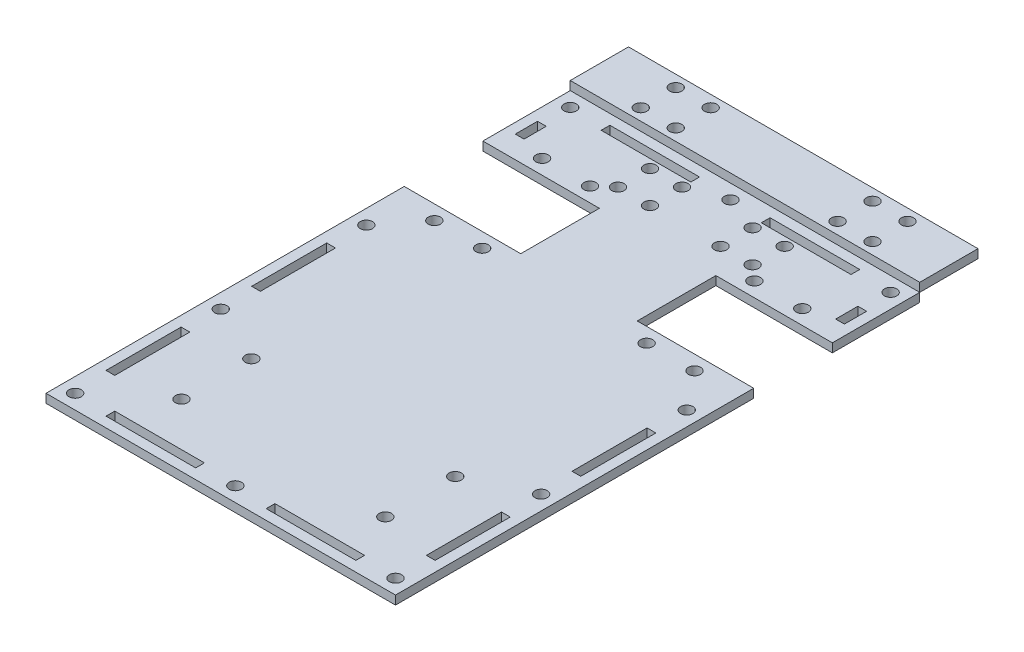
from build123d import *

# Parameters (mm, degrees)
BOSS_EXTRUDE1_DEPTH                     = 3
HOLE_FOR_M3_300_SC_NUTS_SP_1_D          = 4.22
HOLE_FOR_M3_300_SC_NUTS_SP_2_D          = 4.22
HOLE_FOR_M3_300_SC_NUTS_SP_3_D          = 4.22
HOLE_FOR_M3_300_SC_NUTS_SP_4_D          = 4.22
HOLE_FOR_M3_300_SC_NUTS_SP_5_D          = 4.22
SKETCH15_W                              = 30.78
SKETCH15_H                              = 3
SKETCH15_W_2                            = 3
SKETCH15_H_2                            = 7.63
SKETCH15_H_3                            = 25.78
CUT_EXTRUDE1_DEPTH                      = 4
SKETCH16_W                              = 120
SKETCH16_H                              = 20
BOSS_EXTRUDE3_DEPTH                     = 3
SKETCH19_W                              = 2.11
SKETCH19_H                              = 6
HOLE_FOR_M3_300_SC_NUTS_SP_6_AT_2_COUNT = 2
HOLE_FOR_M3_300_SC_NUTS_SP_6_AT_2_PITCH = 12
HOLE_FOR_M3_300_SC_NUTS_SP_6_AT_3_COUNT = 2
HOLE_FOR_M3_300_SC_NUTS_SP_6_AT_3_PITCH = 12
HOLE_FOR_M3_300_SC_NUTS_SP_6_AT_4_COUNT = 2
HOLE_FOR_M3_300_SC_NUTS_SP_6_AT_4_PITCH = 16.970562748
HOLE_FOR_M3_300_SC_NUTS_SP_6_AT_5_COUNT = 2
HOLE_FOR_M3_300_SC_NUTS_SP_6_AT_5_PITCH = 79.58
HOLE_FOR_M3_300_SC_NUTS_SP_6_AT_6_COUNT = 2
HOLE_FOR_M3_300_SC_NUTS_SP_6_AT_6_PITCH = 67.58
HOLE_FOR_M3_300_SC_NUTS_SP_6_AT_7_COUNT = 2
HOLE_FOR_M3_300_SC_NUTS_SP_6_AT_7_PITCH = 68.637135721
HOLE_FOR_M3_300_SC_NUTS_SP_6_AT_8_COUNT = 2
HOLE_FOR_M3_300_SC_NUTS_SP_6_AT_8_PITCH = 80.479664512
SKETCH30_W                              = 2.11
SKETCH30_H                              = 3
HOLE_FOR_M3_300_SC_NUTS_SP_8_AT_2_COUNT = 2
HOLE_FOR_M3_300_SC_NUTS_SP_8_AT_2_PITCH = 11
HOLE_FOR_M3_300_SC_NUTS_SP_8_AT_3_COUNT = 2
HOLE_FOR_M3_300_SC_NUTS_SP_8_AT_3_PITCH = 15.556349186
HOLE_FOR_M3_300_SC_NUTS_SP_8_AT_4_COUNT = 2
HOLE_FOR_M3_300_SC_NUTS_SP_8_AT_4_PITCH = 11
HOLE_FOR_M3_300_SC_NUTS_SP_8_AT_5_COUNT = 2
HOLE_FOR_M3_300_SC_NUTS_SP_8_AT_5_PITCH = 35.22
HOLE_FOR_M3_300_SC_NUTS_SP_8_AT_6_COUNT = 2
HOLE_FOR_M3_300_SC_NUTS_SP_8_AT_6_PITCH = 46.22
HOLE_FOR_M3_300_SC_NUTS_SP_8_AT_7_COUNT = 2
HOLE_FOR_M3_300_SC_NUTS_SP_8_AT_7_PITCH = 47.510929269
HOLE_FOR_M3_300_SC_NUTS_SP_8_AT_8_COUNT = 2
HOLE_FOR_M3_300_SC_NUTS_SP_8_AT_8_PITCH = 36.897810233
SKETCH31_W                              = 40
SKETCH31_H                              = 13
BOSS_EXTRUDE4_DEPTH                     = 3
BOSS_EXTRUDE4_2_DEPTH                   = 3
SKETCH34_W                              = 2.11
SKETCH34_H                              = 3
HOLE_FOR_M3_300_SC_NUTS_SP_9_AT_2_COUNT = 2
HOLE_FOR_M3_300_SC_NUTS_SP_9_AT_2_PITCH = 16.445
HOLE_FOR_M3_300_SC_NUTS_SP_9_AT_3_COUNT = 2
HOLE_FOR_M3_300_SC_NUTS_SP_9_AT_3_PITCH = 72.89
HOLE_FOR_M3_300_SC_NUTS_SP_9_AT_4_COUNT = 2
HOLE_FOR_M3_300_SC_NUTS_SP_9_AT_4_PITCH = 89.335
SKETCH35_W                              = 4.082372286
SKETCH35_H                              = 14.550345667
SKETCH35_W_2                            = 4.333493725
BOSS_EXTRUDE5_DEPTH                     = 3


with BuildPart() as part:
    # Sketch1 → Boss-Extrude1 (new body)
    with BuildSketch(Plane(origin=(0, 0, 0), x_dir=(1, 0, 0), z_dir=(0, 1, 0))):
        Polygon((0, 0), (120, 0), (120, 110), (80, 110), (80, 150), (120, 150), (120, 180), (0, 180), (0, 150), (40, 150), (40, 110), (0, 110), align=None)
    extrude(amount=BOSS_EXTRUDE1_DEPTH)

    # Hole for M3 300® SC Nuts (SP)1 (through all)
    with Locations(Plane(origin=(0, 3, 0), x_dir=(1, 0, 0), z_dir=(0, 1, 0))):
        with Locations((5, 175), (60, 175), (115, 175), (115, 5), (60, 5), (5, 5)):
            Hole(HOLE_FOR_M3_300_SC_NUTS_SP_1_D / 2)

    # Hole for M3 300® SC Nuts (SP)2 (through all)
    with Locations(Plane(origin=(0, 3, 0), x_dir=(1, 0, 0), z_dir=(0, 1, 0))):
        with Locations((5, 105), (115, 105)):
            Hole(HOLE_FOR_M3_300_SC_NUTS_SP_2_D / 2)

    # Hole for M3 300® SC Nuts (SP)3 (through all)
    with Locations(Plane(origin=(0, 3, 0), x_dir=(1, 0, 0), z_dir=(0, 1, 0))):
        with Locations((115, 55), (5, 55)):
            Hole(HOLE_FOR_M3_300_SC_NUTS_SP_3_D / 2)

    # Hole for M3 300® SC Nuts (SP)4 (through all)
    with Locations(Plane(origin=(0, 3, 0), x_dir=(1, 0, 0), z_dir=(0, 1, 0))):
        with Locations((88.2225, 155), (104.6675, 155), (15.3325, 155), (31.7775, 155)):
            Hole(HOLE_FOR_M3_300_SC_NUTS_SP_4_D / 2)

    # Hole for M3 300® SC Nuts (SP)5 (through all)
    with Locations(Plane(origin=(0, 3, 0), x_dir=(1, 0, 0), z_dir=(0, 1, 0))):
        with Locations((25, 45.5), (95, 45.5), (95, 21.5), (25, 21.5)):
            Hole(HOLE_FOR_M3_300_SC_NUTS_SP_5_D / 2)

    # Sketch15 → Cut-Extrude1 (cut, through all)
    with BuildSketch(Plane(origin=(0, 3, 0), x_dir=(1, 0, 0), z_dir=(0, 1, 0))):
        with Locations((87.5, 175)):
            Rectangle(SKETCH15_W, SKETCH15_H)
        with Locations((32.5, 175)):
            Rectangle(SKETCH15_W, SKETCH15_H)
        with Locations((5, 161.445)):
            Rectangle(SKETCH15_W_2, SKETCH15_H_2)
        with Locations((115, 161.445)):
            Rectangle(SKETCH15_W_2, SKETCH15_H_2)
        with Locations((5, 80)):
            Rectangle(SKETCH15_W_2, SKETCH15_H_3)
        with Locations((115, 80)):
            Rectangle(SKETCH15_W_2, SKETCH15_H_3)
        with Locations((115, 30)):
            Rectangle(SKETCH15_W_2, SKETCH15_H_3)
        with Locations((5, 30)):
            Rectangle(SKETCH15_W_2, SKETCH15_H_3)
        with Locations((32.5, 5)):
            Rectangle(SKETCH15_W, SKETCH15_H)
        with Locations((87.5, 5)):
            Rectangle(SKETCH15_W, SKETCH15_H)
    extrude(amount=-CUT_EXTRUDE1_DEPTH, mode=Mode.SUBTRACT)

    # Sketch30 → Hole for M3 300® SC Nuts (SP)8 (revolve, cut)
    with BuildSketch(Plane(origin=(36.89, 3, -159.5), x_dir=(0, 0, 1), z_dir=(1, 0, 0))):
        with Locations((1.055, 1.5)):
            Rectangle(SKETCH30_W, SKETCH30_H)
    hole_for_m3_300_sc_nuts_sp_8 = revolve(axis=Axis((36.89, 9.35, -159.5), (0, -1, 0)), mode=Mode.SUBTRACT)

    # Hole for M3 300® SC Nuts (SP)8 at 2: Hole for M3 300® SC Nuts (SP)8 ×2
    with Locations(*[(0, 0, -i * HOLE_FOR_M3_300_SC_NUTS_SP_8_AT_2_PITCH) for i in range(1, HOLE_FOR_M3_300_SC_NUTS_SP_8_AT_2_COUNT)]):
        add(hole_for_m3_300_sc_nuts_sp_8, mode=Mode.SUBTRACT)

    # Hole for M3 300® SC Nuts (SP)8 at 3: Hole for M3 300® SC Nuts (SP)8 ×2
    with Locations(*[Vector(0.707106781, 0, -0.707106781) * (i * HOLE_FOR_M3_300_SC_NUTS_SP_8_AT_3_PITCH) for i in range(1, HOLE_FOR_M3_300_SC_NUTS_SP_8_AT_3_COUNT)]):
        add(hole_for_m3_300_sc_nuts_sp_8, mode=Mode.SUBTRACT)

    # Hole for M3 300® SC Nuts (SP)8 at 4: Hole for M3 300® SC Nuts (SP)8 ×2
    with Locations(*[(i * HOLE_FOR_M3_300_SC_NUTS_SP_8_AT_4_PITCH, 0, 0) for i in range(1, HOLE_FOR_M3_300_SC_NUTS_SP_8_AT_4_COUNT)]):
        add(hole_for_m3_300_sc_nuts_sp_8, mode=Mode.SUBTRACT)

    # Hole for M3 300® SC Nuts (SP)8 at 5: Hole for M3 300® SC Nuts (SP)8 ×2
    with Locations(*[(i * HOLE_FOR_M3_300_SC_NUTS_SP_8_AT_5_PITCH, 0, 0) for i in range(1, HOLE_FOR_M3_300_SC_NUTS_SP_8_AT_5_COUNT)]):
        add(hole_for_m3_300_sc_nuts_sp_8, mode=Mode.SUBTRACT)

    # Hole for M3 300® SC Nuts (SP)8 at 6: Hole for M3 300® SC Nuts (SP)8 ×2
    with Locations(*[(i * HOLE_FOR_M3_300_SC_NUTS_SP_8_AT_6_PITCH, 0, 0) for i in range(1, HOLE_FOR_M3_300_SC_NUTS_SP_8_AT_6_COUNT)]):
        add(hole_for_m3_300_sc_nuts_sp_8, mode=Mode.SUBTRACT)

    # Hole for M3 300® SC Nuts (SP)8 at 7: Hole for M3 300® SC Nuts (SP)8 ×2
    with Locations(*[Vector(0.972828794, 0, -0.231525676) * (i * HOLE_FOR_M3_300_SC_NUTS_SP_8_AT_7_PITCH) for i in range(1, HOLE_FOR_M3_300_SC_NUTS_SP_8_AT_7_COUNT)]):
        add(hole_for_m3_300_sc_nuts_sp_8, mode=Mode.SUBTRACT)

    # Hole for M3 300® SC Nuts (SP)8 at 8: Hole for M3 300® SC Nuts (SP)8 ×2
    with Locations(*[Vector(0.95452819, 0, -0.298120672) * (i * HOLE_FOR_M3_300_SC_NUTS_SP_8_AT_8_PITCH) for i in range(1, HOLE_FOR_M3_300_SC_NUTS_SP_8_AT_8_COUNT)]):
        add(hole_for_m3_300_sc_nuts_sp_8, mode=Mode.SUBTRACT)



with BuildPart() as body_2:
    # Sketch16 → Boss-Extrude3 (new body)
    with BuildSketch(Plane(origin=(0, 3, 0), x_dir=(1, 0, 0), z_dir=(0, 1, 0))):
        with Locations((60, 190)):
            Rectangle(SKETCH16_W, SKETCH16_H)
    extrude(amount=BOSS_EXTRUDE3_DEPTH)

    # Sketch19 → Hole for M3 300® SC Nuts (SP)6 (revolve, cut)
    with BuildSketch(Plane(origin=(20.21, 6, -196), x_dir=(0, 0, 1), z_dir=(1, 0, 0))):
        with Locations((1.055, 3)):
            Rectangle(SKETCH19_W, SKETCH19_H)
    hole_for_m3_300_sc_nuts_sp_6 = revolve(axis=Axis((20.21, 12.35, -196), (0, -1, 0)), mode=Mode.SUBTRACT)

    # Hole for M3 300® SC Nuts (SP)6 at 2: Hole for M3 300® SC Nuts (SP)6 ×2
    with Locations(*[(i * HOLE_FOR_M3_300_SC_NUTS_SP_6_AT_2_PITCH, 0, 0) for i in range(1, HOLE_FOR_M3_300_SC_NUTS_SP_6_AT_2_COUNT)]):
        add(hole_for_m3_300_sc_nuts_sp_6, mode=Mode.SUBTRACT)

    # Hole for M3 300® SC Nuts (SP)6 at 3: Hole for M3 300® SC Nuts (SP)6 ×2
    with Locations(*[(0, 0, i * HOLE_FOR_M3_300_SC_NUTS_SP_6_AT_3_PITCH) for i in range(1, HOLE_FOR_M3_300_SC_NUTS_SP_6_AT_3_COUNT)]):
        add(hole_for_m3_300_sc_nuts_sp_6, mode=Mode.SUBTRACT)

    # Hole for M3 300® SC Nuts (SP)6 at 4: Hole for M3 300® SC Nuts (SP)6 ×2
    with Locations(*[Vector(0.707106781, 0, 0.707106781) * (i * HOLE_FOR_M3_300_SC_NUTS_SP_6_AT_4_PITCH) for i in range(1, HOLE_FOR_M3_300_SC_NUTS_SP_6_AT_4_COUNT)]):
        add(hole_for_m3_300_sc_nuts_sp_6, mode=Mode.SUBTRACT)

    # Hole for M3 300® SC Nuts (SP)6 at 5: Hole for M3 300® SC Nuts (SP)6 ×2
    with Locations(*[(i * HOLE_FOR_M3_300_SC_NUTS_SP_6_AT_5_PITCH, 0, 0) for i in range(1, HOLE_FOR_M3_300_SC_NUTS_SP_6_AT_5_COUNT)]):
        add(hole_for_m3_300_sc_nuts_sp_6, mode=Mode.SUBTRACT)

    # Hole for M3 300® SC Nuts (SP)6 at 6: Hole for M3 300® SC Nuts (SP)6 ×2
    with Locations(*[(i * HOLE_FOR_M3_300_SC_NUTS_SP_6_AT_6_PITCH, 0, 0) for i in range(1, HOLE_FOR_M3_300_SC_NUTS_SP_6_AT_6_COUNT)]):
        add(hole_for_m3_300_sc_nuts_sp_6, mode=Mode.SUBTRACT)

    # Hole for M3 300® SC Nuts (SP)6 at 7: Hole for M3 300® SC Nuts (SP)6 ×2
    with Locations(*[Vector(0.984598196, 0, 0.17483247) * (i * HOLE_FOR_M3_300_SC_NUTS_SP_6_AT_7_PITCH) for i in range(1, HOLE_FOR_M3_300_SC_NUTS_SP_6_AT_7_COUNT)]):
        add(hole_for_m3_300_sc_nuts_sp_6, mode=Mode.SUBTRACT)

    # Hole for M3 300® SC Nuts (SP)6 at 8: Hole for M3 300® SC Nuts (SP)6 ×2
    with Locations(*[Vector(0.988821219, 0, 0.149105989) * (i * HOLE_FOR_M3_300_SC_NUTS_SP_6_AT_8_PITCH) for i in range(1, HOLE_FOR_M3_300_SC_NUTS_SP_6_AT_8_COUNT)]):
        add(hole_for_m3_300_sc_nuts_sp_6, mode=Mode.SUBTRACT)


with BuildPart() as body_3:
    # Sketch31 → Boss-Extrude4 (new body)
    with BuildSketch(Plane(origin=(0, 3, 0), x_dir=(1, 0, 0), z_dir=(0, 1, 0))):
        with Locations((20, 116.5)):
            Rectangle(SKETCH31_W, SKETCH31_H)
    extrude(amount=-BOSS_EXTRUDE4_DEPTH)

    # Sketch34 → Hole for M3 300® SC Nuts (SP)9 (revolve, cut)
    with BuildSketch(Plane(origin=(15.3325, 3, -118), x_dir=(0, 0, 1), z_dir=(1, 0, 0))):
        with Locations((1.055, 1.5)):
            Rectangle(SKETCH34_W, SKETCH34_H)
    hole_for_m3_300_sc_nuts_sp_9 = revolve(axis=Axis((15.3325, 9.35, -118), (0, -1, 0)), mode=Mode.SUBTRACT)

    # Hole for M3 300® SC Nuts (SP)9 at 2: Hole for M3 300® SC Nuts (SP)9 ×2
    with Locations(*[(i * HOLE_FOR_M3_300_SC_NUTS_SP_9_AT_2_PITCH, 0, 0) for i in range(1, HOLE_FOR_M3_300_SC_NUTS_SP_9_AT_2_COUNT)]):
        add(hole_for_m3_300_sc_nuts_sp_9, mode=Mode.SUBTRACT)


with BuildPart() as body_4:
    # Sketch31 → Boss-Extrude4 2 (new body)
    with BuildSketch(Plane(origin=(0, 3, 0), x_dir=(1, 0, 0), z_dir=(0, 1, 0))):
        with Locations((100, 116.5)):
            Rectangle(SKETCH31_W, SKETCH31_H)
    extrude(amount=-BOSS_EXTRUDE4_2_DEPTH)

    # Hole for M3 300® SC Nuts (SP)9 at 3: Hole for M3 300® SC Nuts (SP)9 ×2
    with Locations(*[(i * HOLE_FOR_M3_300_SC_NUTS_SP_9_AT_3_PITCH, 0, 0) for i in range(1, HOLE_FOR_M3_300_SC_NUTS_SP_9_AT_3_COUNT)]):
        add(hole_for_m3_300_sc_nuts_sp_9, mode=Mode.SUBTRACT)

    # Hole for M3 300® SC Nuts (SP)9 at 4: Hole for M3 300® SC Nuts (SP)9 ×2
    with Locations(*[(i * HOLE_FOR_M3_300_SC_NUTS_SP_9_AT_4_PITCH, 0, 0) for i in range(1, HOLE_FOR_M3_300_SC_NUTS_SP_9_AT_4_COUNT)]):
        add(hole_for_m3_300_sc_nuts_sp_9, mode=Mode.SUBTRACT)


with BuildPart() as part_1:
    add(part.part)

    add(body_3.part)  # Boss-Extrude5 merges body 3

    add(body_4.part)  # Boss-Extrude5 merges body 4
    # Sketch35 → Boss-Extrude5 (add)
    with BuildSketch(Plane(origin=(0, 3, 0), x_dir=(1, 0, 0), z_dir=(0, 1, 0))):
        with Locations((39.270197702, 115.724827167)):
            Rectangle(SKETCH35_W, SKETCH35_H)
        with Locations((80.634950419, 115.724827167)):
            Rectangle(SKETCH35_W_2, SKETCH35_H)
    extrude(amount=-BOSS_EXTRUDE5_DEPTH)


solid = Compound([body_2.part, part_1.part])
